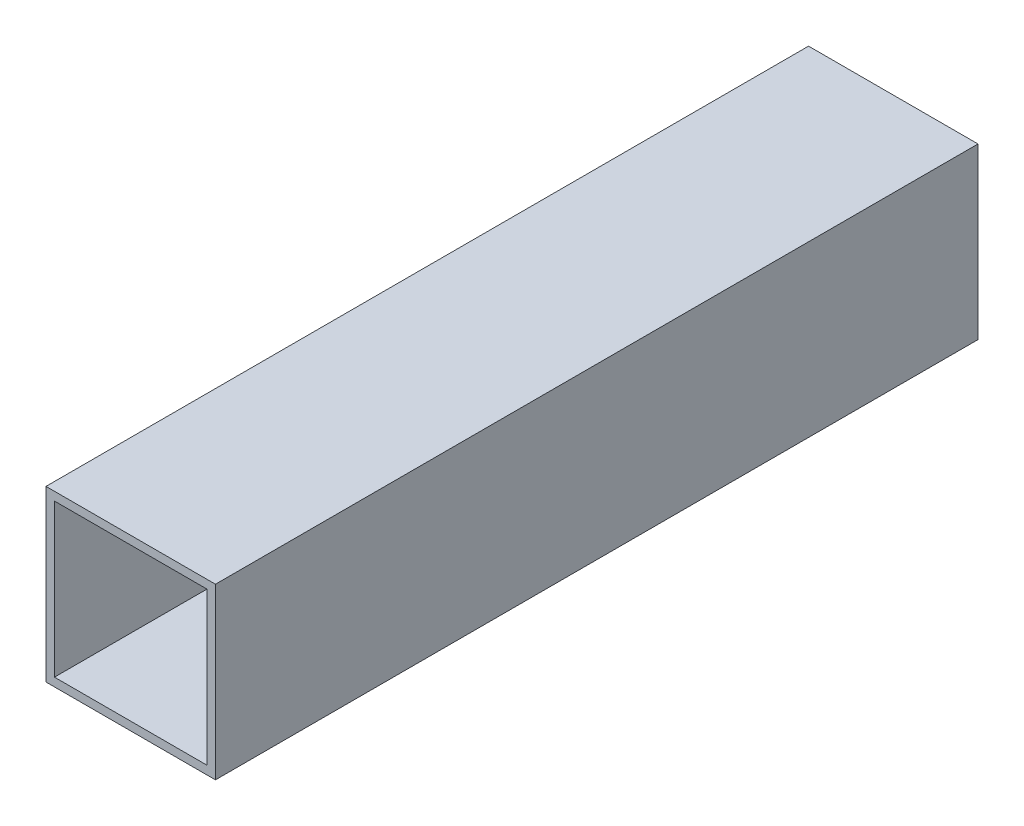
from build123d import *

# Parameters (mm, degrees)
SKETCH1_W           = 100
SKETCH1_H           = 100
SKETCH1_W_2         = 90
SKETCH1_H_2         = 90
BOSS_EXTRUDE1_DEPTH = 225


with BuildPart() as part:
    # Sketch1 → Boss-Extrude1 (new body, symmetric)
    with BuildSketch(Plane.XY):
        Rectangle(SKETCH1_W, SKETCH1_H)
        Rectangle(SKETCH1_W_2, SKETCH1_H_2, mode=Mode.SUBTRACT)
    extrude(amount=BOSS_EXTRUDE1_DEPTH, both=True)


solid = part.part
